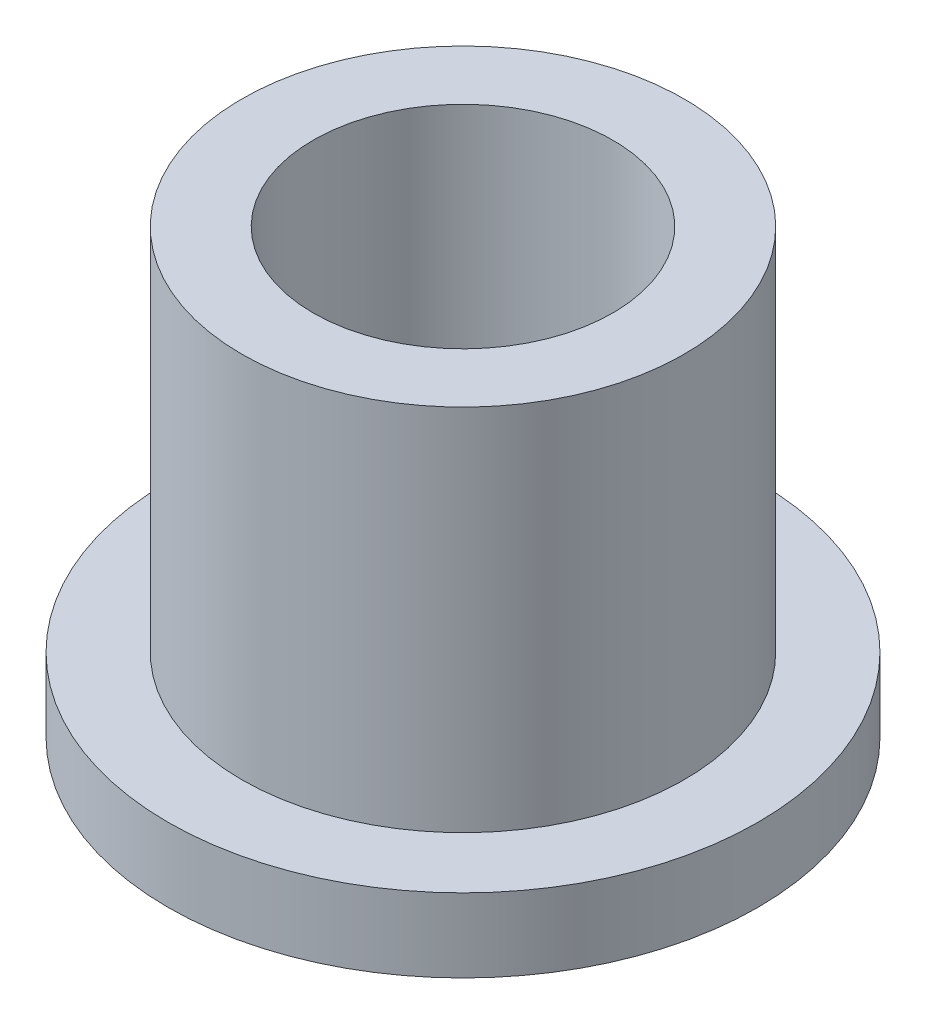
from build123d import *

# Parameters (mm, degrees)
SKETCH2_R           = 4.7625
SKETCH2_R_2         = 3.2258
BOSS_EXTRUDE1_DEPTH = 9.525
SKETCH3_R           = 6.35
SKETCH3_R_2         = 4.7625
BOSS_EXTRUDE2_DEPTH = 1.5875


with BuildPart() as part:
    # Sketch2 → Boss-Extrude1 (new body)
    with BuildSketch(Plane(origin=(0, 0, 0), x_dir=(1, 0, 0), z_dir=(0, 1, 0))):
        Circle(SKETCH2_R)
        Circle(SKETCH2_R_2, mode=Mode.SUBTRACT)
    extrude(amount=BOSS_EXTRUDE1_DEPTH)

    # Sketch3 → Boss-Extrude2 (add)
    with BuildSketch(Plane(origin=(0, 0, 0), x_dir=(1, 0, 0), z_dir=(0, 1, 0))):
        Circle(SKETCH3_R)
        Circle(SKETCH3_R_2, mode=Mode.SUBTRACT)
    extrude(amount=BOSS_EXTRUDE2_DEPTH)


solid = part.part
